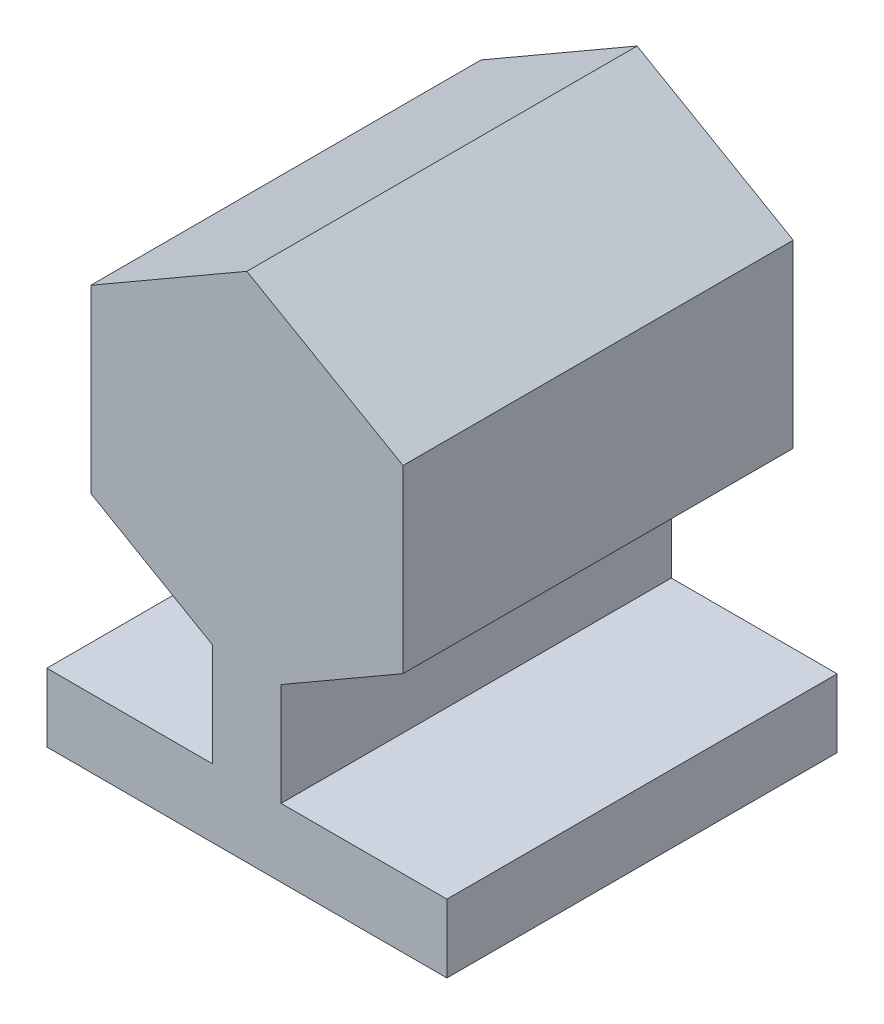
from build123d import *

# Parameters (mm, degrees)
BOSS_EXTRUDE1_DEPTH = 200000


with BuildPart() as part:
    # Sketch1 → Boss-Extrude1 (new body)
    with BuildSketch(Plane.XY):
        Polygon((0, 92376.04307034), (-80000, 46188.02153517), (-80000, -46188.02153517), (-17500, -82272.413359522), (-17500, -135000), (-102500, -135000), (-102500, -170000), (102500, -170000), (102500, -135000), (17500, -135000), (17500, -82272.413359522), (80000, -46188.02153517), (80000, 46188.02153517), align=None)
    extrude(amount=BOSS_EXTRUDE1_DEPTH)


solid = part.part
